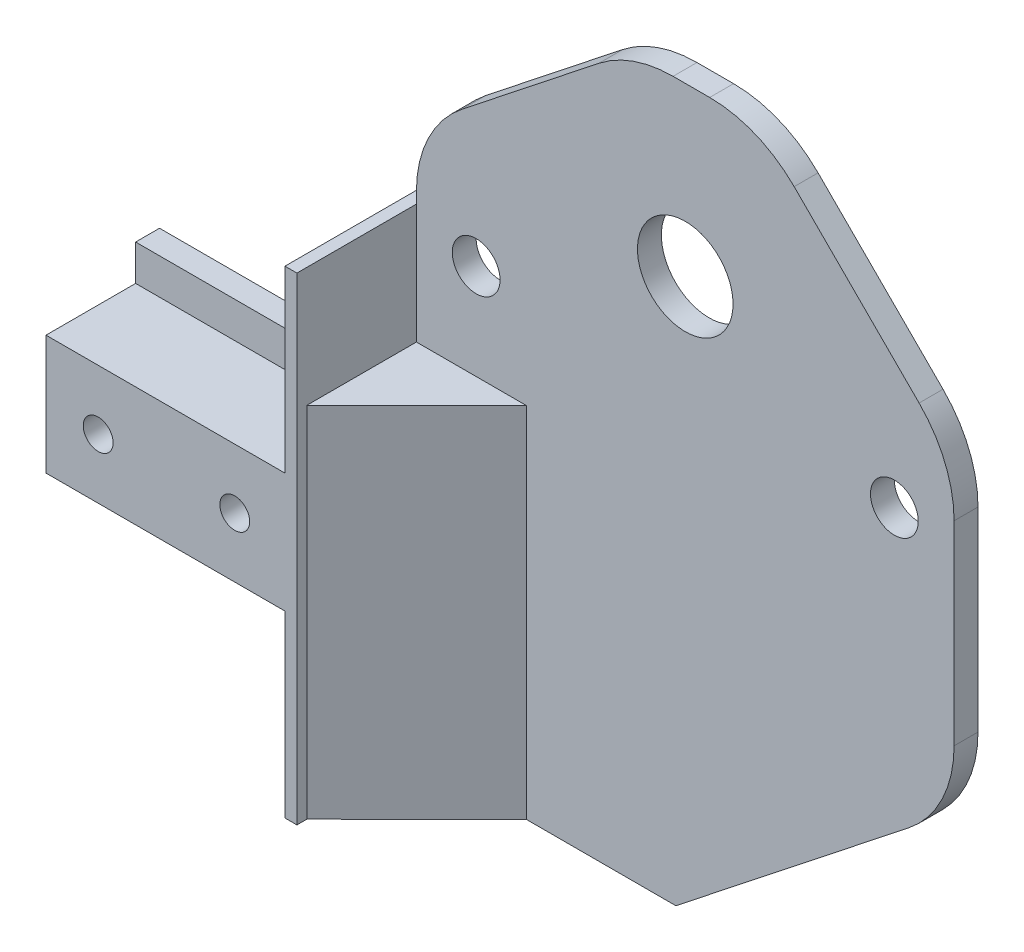
from build123d import *

# Parameters (mm, degrees)
SKETCH2_W                = 20
SKETCH2_H                = 10
BOSS_EXTRUDE1_DEPTH      = 11
SKETCH3_W                = 20
SKETCH3_H                = 2
BOSS_EXTRUDE2_DEPTH      = 3
BOSS_EXTRUDE2_DEPTH_BACK = 13
SKETCH4_W                = 12
SKETCH4_H                = 40
BOSS_EXTRUDE3_DEPTH      = 1
SKETCH5_W                = 2
SKETCH5_H                = 60
BOSS_EXTRUDE4_DEPTH      = 45
F_4_0MM_DOWEL_SLOT1_D    = 4
F_8_0MM_DOWEL_SLOT4_D    = 8
SKETCH22_W               = 9.202465877
SKETCH22_H               = 9.167340884
BOSS_EXTRUDE5_DEPTH      = 0.001
BOSS_EXTRUDE5_DEPTH_BACK = 30
CUT_EXTRUDE1_DEPTH       = 31
F_2_5MM_DOWEL_SLOT1_D    = 2.5
CUT_EXTRUDE2_DEPTH       = 10
CUT_EXTRUDE3_DEPTH       = 10
FILLET1_R                = 10


with BuildPart() as part:
    # Sketch2 → Boss-Extrude1 (new body)
    with BuildSketch(Plane.XY):
        Rectangle(SKETCH2_W, SKETCH2_H)
    extrude(amount=BOSS_EXTRUDE1_DEPTH)

    # Sketch3 → Boss-Extrude2 (add, two sides)
    with BuildSketch(Plane(origin=(0, 5, 0), x_dir=(1, 0, 0), z_dir=(0, 1, 0))) as boss_extrude2_sk:
        with Locations((0, -2.5)):
            Rectangle(SKETCH3_W, SKETCH3_H)
    extrude(amount=BOSS_EXTRUDE2_DEPTH)
    extrude(boss_extrude2_sk.sketch, amount=-BOSS_EXTRUDE2_DEPTH_BACK)

    # Sketch4 → Boss-Extrude3 (add)
    with BuildSketch(Plane(origin=(10, 0, 0), x_dir=(0, 0, -1), z_dir=(1, 0, 0))):
        with Locations((-5, 0)):
            Rectangle(SKETCH4_W, SKETCH4_H)
    extrude(amount=BOSS_EXTRUDE3_DEPTH)

    # Sketch5 → Boss-Extrude4 (add)
    with BuildSketch(Plane(origin=(11, 0, 0), x_dir=(0, 0, -1), z_dir=(1, 0, 0))):
        with Locations((0, 10)):
            Rectangle(SKETCH5_W, SKETCH5_H)
    extrude(amount=BOSS_EXTRUDE4_DEPTH)

    # Ø4.0mm Dowel Slot1 (through all)
    with Locations(Plane.XY.offset(1)):
        with Locations((16, 18), (51, 18)):
            Hole(F_4_0MM_DOWEL_SLOT1_D / 2)

    # Ø8.0mm Dowel Slot4 (through all)
    with Locations(Plane.XY.offset(1)):
        with Locations((33.5, 26)):
            Hole(F_8_0MM_DOWEL_SLOT4_D / 2)

    # Sketch22 → Boss-Extrude5 (add, two sides)
    with BuildSketch(Plane(origin=(11, -20, 1), x_dir=(-1, 0, 0), z_dir=(0, -1, 0))) as boss_extrude5_sk:
        with Locations((-4.601232938, -4.583670442)):
            Rectangle(SKETCH22_W, SKETCH22_H)
    extrude(amount=BOSS_EXTRUDE5_DEPTH)
    extrude(boss_extrude5_sk.sketch, amount=-BOSS_EXTRUDE5_DEPTH_BACK)

    # Sketch23 → Cut-Extrude1 (cut)
    with BuildSketch(Plane(origin=(0, 10, 0), x_dir=(1, 0, 0), z_dir=(0, 1, 0))):
        Polygon((20.202465877, -1), (11, -10.167340884), (20.202465877, -10.167340884), align=None)
    extrude(amount=-CUT_EXTRUDE1_DEPTH, mode=Mode.SUBTRACT)

    # Ø2.5mm Dowel Slot1 (through all)
    with Locations(Plane.XY.offset(11)):
        with Locations((-5.633536512, 0), (5.798014949, 0)):
            Hole(F_2_5MM_DOWEL_SLOT1_D / 2)

    # Sketch26 → Cut-Extrude2 (cut)
    with BuildSketch(Plane.XY.offset(1)):
        Polygon((29.003862236, 40), (11, 25.763222488), (11, 40), align=None)
        Polygon((56, 40), (39.686791896, 40), (56, 23.686791896), align=None)
    extrude(amount=-CUT_EXTRUDE2_DEPTH, mode=Mode.SUBTRACT)

    # Sketch27 → Cut-Extrude3 (cut)
    with BuildSketch(Plane.XY.offset(1)):
        Polygon((32.71386297, -20), (56, -1.611523644), (56, -20), align=None)
    extrude(amount=-CUT_EXTRUDE3_DEPTH, mode=Mode.SUBTRACT)

    # Fillet1
    fillet1_edges = [part.edges().sort_by_distance(p)[0] for p in [
        (29.003862236, 40, 0),
        (11, 25.763222488, 0),
        (56, 23.686791896, 0),
        (39.686791896, 40, 0),
        (56, -1.611523644, 0),
    ]]
    fillet(fillet1_edges, radius=FILLET1_R)


solid = part.part
